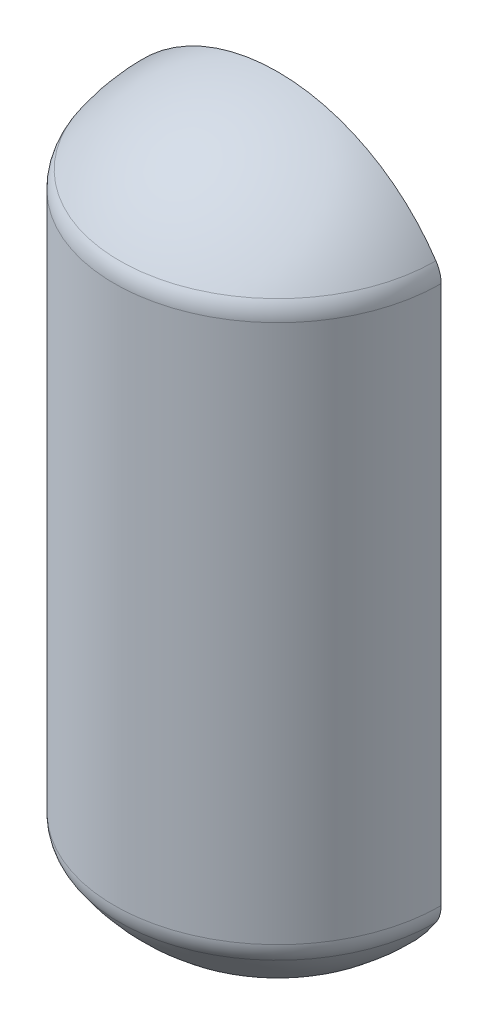
from build123d import *

# Parameters (mm, degrees)
REVOLVE1_ANGLE = 180
FILLET1_R      = 25.4


with BuildPart() as part:
    # Sketch1 → Revolve1 (revolve)
    with BuildSketch(Plane.XY):
        with BuildLine():
            Line((0, 3.175), (0, 0))
            ThreePointArc((0, 0), (-77.068833235, 20.382447395), (-133.985, 76.2))
            Line((-133.985, 76.2), (-133.985, 532.7))
            ThreePointArc((-133.985, 532.7), (-77.068833235, 588.517552605), (0, 608.9))
            Line((0, 608.9), (0, 605.725))
            ThreePointArc((0, 605.725), (-75.121348346, 585.971864985), (-130.81, 531.822281449))
            Line((-130.81, 531.822281449), (-130.81, 77.077718551))
            ThreePointArc((-130.81, 77.077718551), (-75.121348346, 22.928135015), (0, 3.175))
        make_face()
        with BuildLine():
            Line((0, 3.175), (0, 605.725))
            ThreePointArc((0, 605.725), (-75.121348346, 585.971864985), (-130.81, 531.822281449))
            Line((-130.81, 531.822281449), (-130.81, 77.077718551))
            ThreePointArc((-130.81, 77.077718551), (-75.121348346, 22.928135015), (0, 3.175))
        make_face()
    revolve(axis=Axis((0, 0, 0), (0, 1, 0)), revolution_arc=REVOLVE1_ANGLE)

    # Fillet1
    fillet1_edges = [part.edges().sort_by_distance(p)[0] for p in [
        (0, 76.2, 133.985),
        (0, 532.7, 133.985),
    ]]
    fillet(fillet1_edges, radius=FILLET1_R)


solid = part.part
